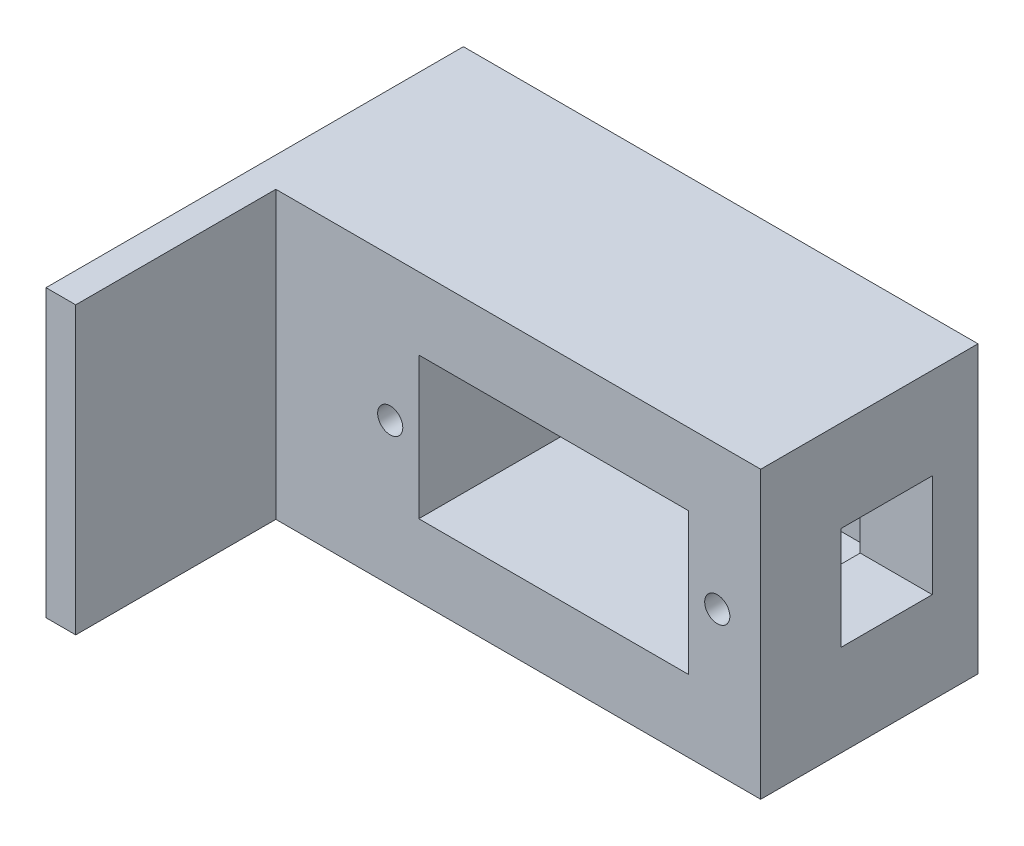
from build123d import *

# Parameters (mm, degrees)
SKETCH_1_W          = 45
SKETCH_1_H          = 25
EXTRUDE_2_DEPTH     = 19
SKETCH_4_W          = 23.6
SKETCH_4_H          = 12.4
CUT_EXTRUDE_2_DEPTH = 17.5
SKETCH_5_W          = 8
SKETCH_5_H          = 9
CUT_EXTRUDE_4_DEPTH = 7
SKETCH_6_R          = 1.1
CUT_EXTRUDE_6_DEPTH = 7.5
SKETCH_8_W          = 2.6
SKETCH_8_H          = 25
EXTRUDE_3_DEPTH     = 17.5


with BuildPart() as part:
    # 草圖1 → 填料-伸長2 (new body)
    with BuildSketch(Plane.XY):
        with Locations((-42.528991691, -4.596431101)):
            Rectangle(SKETCH_1_W, SKETCH_1_H)
    extrude(amount=EXTRUDE_2_DEPTH)

    # 草圖4 → 除料-伸長2 (cut)
    with BuildSketch(Plane.XY.offset(19)):
        with Locations((-38.128991691, -4.596431101)):
            Rectangle(SKETCH_4_W, SKETCH_4_H)
    extrude(amount=-CUT_EXTRUDE_2_DEPTH, mode=Mode.SUBTRACT)

    # 草圖5 → 除料-伸長4 (cut)
    with BuildSketch(Plane(origin=(-20.028991691, 0, 0), x_dir=(0, 0, -1), z_dir=(1, 0, 0))):
        with Locations((-8, -4.596431101)):
            Rectangle(SKETCH_5_W, SKETCH_5_H)
    extrude(amount=-CUT_EXTRUDE_4_DEPTH, mode=Mode.SUBTRACT)

    # 草圖6 → 除料-伸長6 (cut)
    with BuildSketch(Plane.XY.offset(19)):
        with Locations((-23.828991691, -4.596431101)):
            Circle(SKETCH_6_R)
        with Locations((-52.428991691, -4.596431101)):
            Circle(SKETCH_6_R)
    extrude(amount=-CUT_EXTRUDE_6_DEPTH, mode=Mode.SUBTRACT)

    # 草圖8 → 填料-伸長3 (add)
    with BuildSketch(Plane.XY.offset(19)):
        with Locations((-63.728991691, -4.596431101)):
            Rectangle(SKETCH_8_W, SKETCH_8_H)
    extrude(amount=EXTRUDE_3_DEPTH)


solid = part.part
